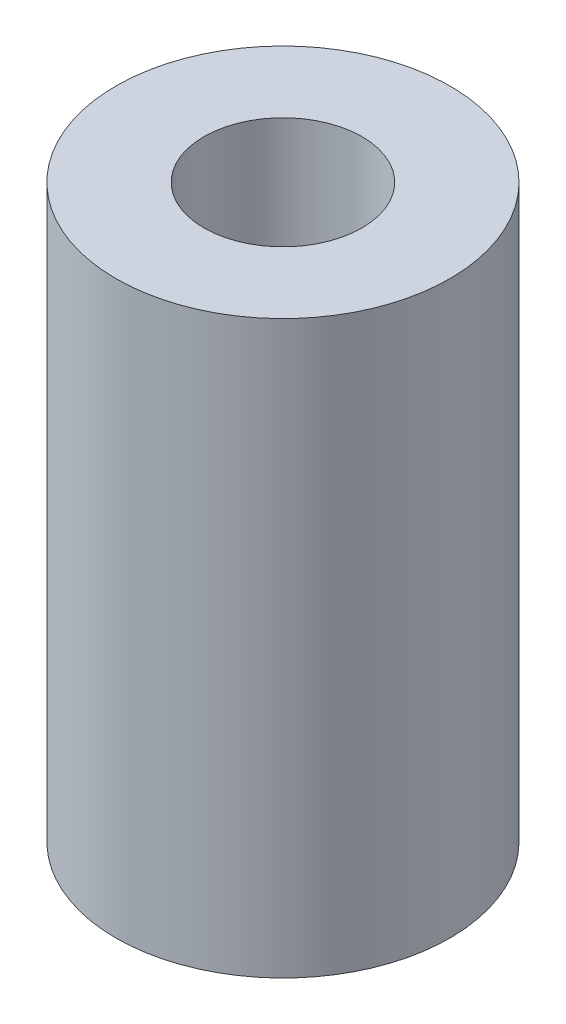
from build123d import *

# Parameters (mm, degrees)
SKETCH1_R           = 3.8
SKETCH1_R_2         = 1.8
BOSS_EXTRUDE1_DEPTH = 13


with BuildPart() as part:
    # Sketch1 → Boss-Extrude1 (new body)
    with BuildSketch(Plane(origin=(0, 0, 0), x_dir=(1, 0, 0), z_dir=(0, 1, 0))):
        Circle(SKETCH1_R)
        Circle(SKETCH1_R_2, mode=Mode.SUBTRACT)
    extrude(amount=BOSS_EXTRUDE1_DEPTH)


solid = part.part
